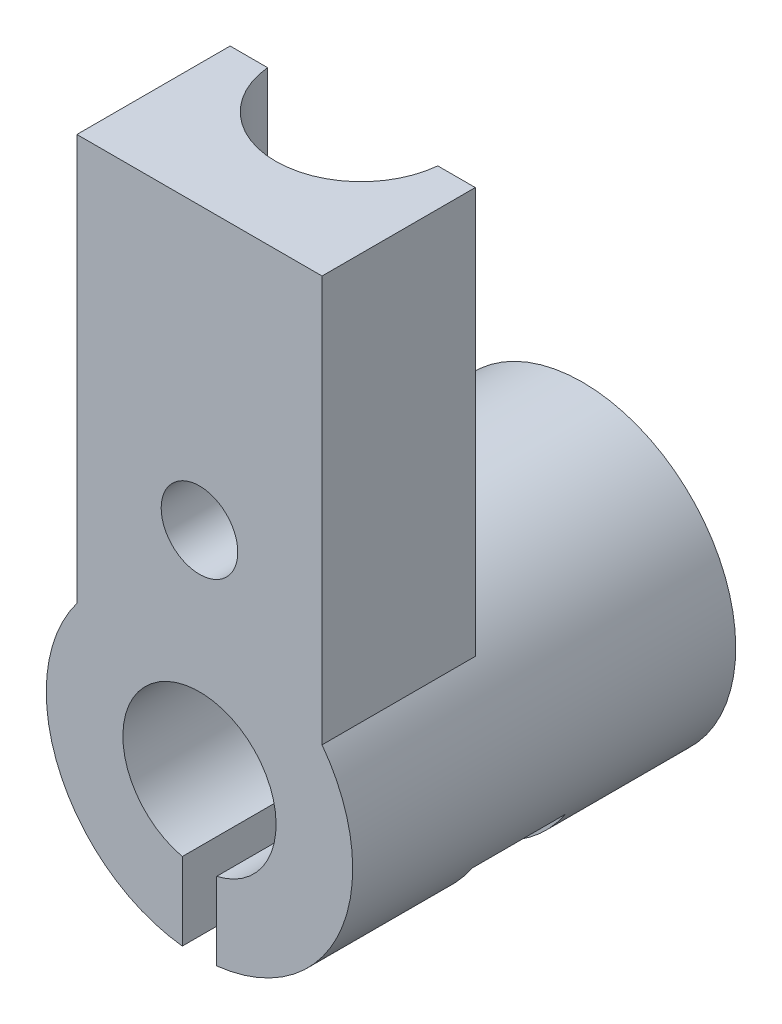
from build123d import *

# Parameters (mm, degrees)
SKETCH1_R           = 20
SKETCH1_R_2         = 10
BOSS_EXTRUDE2_DEPTH = 50
BOSS_EXTRUDE3_REACH = 87
SKETCH4_W           = 32
SKETCH4_H           = 20
SKETCH5_R           = 11.161512364
CUT_EXTRUDE1_DEPTH  = 25
SKETCH7_W           = 4.481872956
SKETCH7_H           = 18.163379873
CUT_EXTRUDE2_DEPTH  = 51
SKETCH9_R           = 5
CUT_EXTRUDE3_DEPTH  = 21
CUT_EXTRUDE4_START  = 19
SKETCH10_W          = 12.248004276
SKETCH10_H          = 7.5
CUT_EXTRUDE4_DEPTH  = 15
SKETCH11_R          = 3
CUT_EXTRUDE5_DEPTH  = 25


with BuildPart() as part:
    # Sketch1 → Boss-Extrude2 (new body)
    with BuildSketch(Plane.XY):
        Circle(SKETCH1_R)
        Circle(SKETCH1_R_2, mode=Mode.SUBTRACT)
    extrude(amount=BOSS_EXTRUDE2_DEPTH)

    # Sketch4 → Boss-Extrude3 (add, up to next)
    with BuildSketch(Plane(origin=(0, 65, 0), x_dir=(1, 0, 0), z_dir=(0, 1, 0)), mode=Mode.PRIVATE) as boss_extrude3_sk1:
        with Locations((0, -40)):
            Rectangle(SKETCH4_W, SKETCH4_H)
    boss_extrude3_tool1 = extrude(boss_extrude3_sk1.sketch, amount=-BOSS_EXTRUDE3_REACH, mode=Mode.PRIVATE) - part.part
    add(boss_extrude3_tool1.solids().sort_by_distance((0, 65, 40))[0])

    # Sketch5 → Cut-Extrude1 (cut)
    with BuildSketch(Plane(origin=(0, 65, 0), x_dir=(1, 0, 0), z_dir=(0, 1, 0))):
        with Locations((0, -28.900111213)):
            Circle(SKETCH5_R)
    extrude(amount=-CUT_EXTRUDE1_DEPTH, mode=Mode.SUBTRACT)

    # Sketch7 → Cut-Extrude2 (cut, through all)
    with BuildSketch(Plane(origin=(0, 0, 0), x_dir=(-1, 0, 0), z_dir=(0, 0, -1))):
        with Locations((0, -15.183116037)):
            Rectangle(SKETCH7_W, SKETCH7_H)
    extrude(amount=-CUT_EXTRUDE2_DEPTH, mode=Mode.SUBTRACT)

    # Sketch9 → Cut-Extrude3 (cut, through all)
    with BuildSketch(Plane(origin=(0, 0, 30), x_dir=(-1, 0, 0), z_dir=(0, 0, -1))):
        with Locations((0, 28.274780399)):
            Circle(SKETCH9_R)
    extrude(amount=-CUT_EXTRUDE3_DEPTH, mode=Mode.SUBTRACT)

    # Sketch10 → Cut-Extrude4 (cut)
    with BuildSketch(Plane(origin=(0, 0, 0), x_dir=(0, 0, -1), z_dir=(1, 0, 0)).offset(CUT_EXTRUDE4_START)):
        with Locations((-25, -14.823528739)):
            Rectangle(SKETCH10_W, SKETCH10_H)
    cut_extrude4 = extrude(amount=-CUT_EXTRUDE4_DEPTH, mode=Mode.SUBTRACT)

    # Mirror1: Cut-Extrude4 across plane
    add(cut_extrude4.mirror(Plane(origin=(0, 0, 0), x_dir=(0, 0, 1), z_dir=(1, 0, 0))), mode=Mode.SUBTRACT)

    # Sketch11 → Cut-Extrude5 (cut, through all)
    with BuildSketch(Plane.ZY.offset(4)):
        with Locations((25, -14.823528739)):
            Circle(SKETCH11_R)
    extrude(amount=-CUT_EXTRUDE5_DEPTH, mode=Mode.SUBTRACT)


solid = part.part
